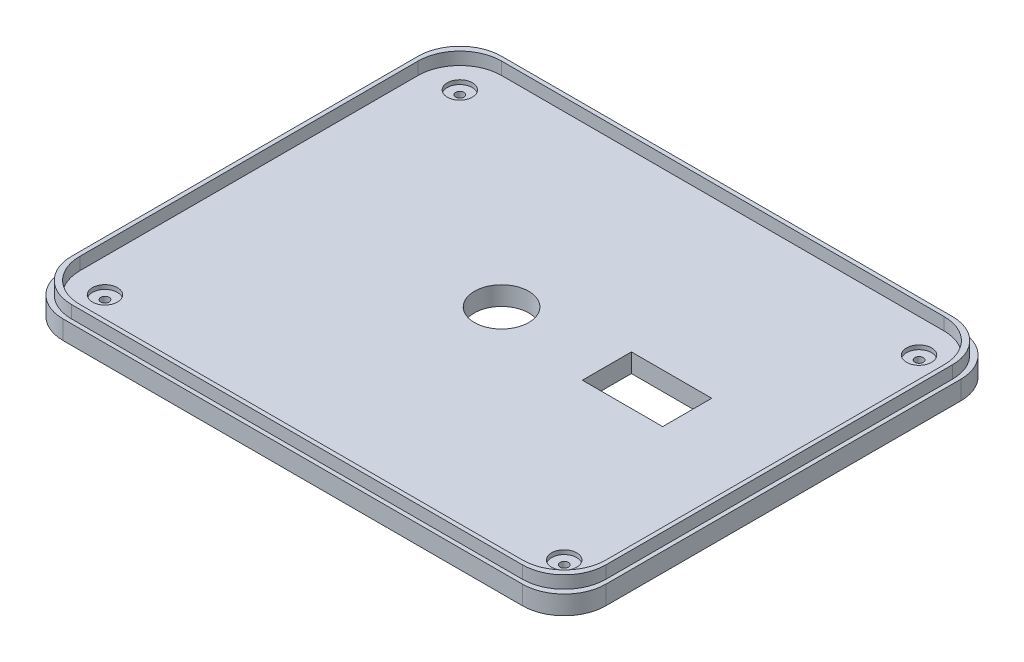
from build123d import *

# Parameters (mm, degrees)
SKETCH_1_R          = 6.5
EXTRUDE_1_DEPTH     = 4.5
EXTRUDE_2_DEPTH     = 3
SKETCH_3_R          = 1
CUT_EXTRUDE_1_DEPTH = 10
SKETCH_4_R          = 3
CUT_EXTRUDE_2_DEPTH = 1
SKETCH_5_R          = 3
CUT_EXTRUDE_3_DEPTH = 1.5
SKETCH_6_W          = 19.238645782
SKETCH_6_H          = 11.749776954
CUT_EXTRUDE_6_DEPTH = 10


with BuildPart() as part:
    # 草图1 → 凸台-拉伸1 (new body)
    with BuildSketch(Plane(origin=(0, 0, 0), x_dir=(1, 0, 0), z_dir=(0, 1, 0))):
        with BuildLine():
            Line((-50.483870968, 65.483870968), (59.516129032, 65.483870968))
            ThreePointArc((59.516129032, 65.483870968), (66.587196844, 62.55493878), (69.516129032, 55.483870968))
            Line((69.516129032, 55.483870968), (69.516129032, -29.516129032))
            ThreePointArc((69.516129032, -29.516129032), (66.587196844, -36.587196844), (59.516129032, -39.516129032))
            Line((59.516129032, -39.516129032), (-50.483870968, -39.516129032))
            ThreePointArc((-50.483870968, -39.516129032), (-57.55493878, -36.587196844), (-60.483870968, -29.516129032))
            Line((-60.483870968, -29.516129032), (-60.483870968, 55.483870968))
            ThreePointArc((-60.483870968, 55.483870968), (-57.55493878, 62.55493878), (-50.483870968, 65.483870968))
        make_face()
        with Locations((-0.483870968, 15.483870968)):
            Circle(SKETCH_1_R, mode=Mode.SUBTRACT)
    extrude(amount=EXTRUDE_1_DEPTH)

    # 草图2 → 凸台-拉伸2 (add)
    with BuildSketch(Plane(origin=(0, 4.5, 0), x_dir=(1, 0, 0), z_dir=(0, 1, 0))):
        with BuildLine():
            Line((-49.483870968, 64.483870968), (58.516129032, 64.483870968))
            ThreePointArc((58.516129032, 64.483870968), (65.587196844, 61.55493878), (68.516129032, 54.483870968))
            Line((68.516129032, 54.483870968), (68.516129032, -28.516129032))
            ThreePointArc((68.516129032, -28.516129032), (65.587196844, -35.587196844), (58.516129032, -38.516129032))
            Line((58.516129032, -38.516129032), (-49.483870968, -38.516129032))
            ThreePointArc((-49.483870968, -38.516129032), (-56.55493878, -35.587196844), (-59.483870968, -28.516129032))
            Line((-59.483870968, -28.516129032), (-59.483870968, 54.483870968))
            ThreePointArc((-59.483870968, 54.483870968), (-56.55493878, 61.55493878), (-49.483870968, 64.483870968))
        make_face()
        with BuildLine():
            Line((-48.483870968, 63.483870968), (57.516129032, 63.483870968))
            ThreePointArc((57.516129032, 63.483870968), (64.587196844, 60.55493878), (67.516129032, 53.483870968))
            Line((67.516129032, 53.483870968), (67.516129032, -27.516129032))
            ThreePointArc((67.516129032, -27.516129032), (64.587196844, -34.587196844), (57.516129032, -37.516129032))
            Line((57.516129032, -37.516129032), (-48.483870968, -37.516129032))
            ThreePointArc((-48.483870968, -37.516129032), (-55.55493878, -34.587196844), (-58.483870968, -27.516129032))
            Line((-58.483870968, -27.516129032), (-58.483870968, 53.483870968))
            ThreePointArc((-58.483870968, 53.483870968), (-55.55493878, 60.55493878), (-48.483870968, 63.483870968))
        make_face(mode=Mode.SUBTRACT)
    extrude(amount=EXTRUDE_2_DEPTH)

    # 草图3 → 切除-拉伸1 (cut)
    with BuildSketch(Plane(origin=(0, 4.5, 0), x_dir=(1, 0, 0), z_dir=(0, 1, 0))):
        with Locations((-50.483870968, 55.483870968)):
            Circle(SKETCH_3_R)
        with Locations((-50.483870968, -29.516129032)):
            Circle(SKETCH_3_R)
        with Locations((59.516129032, -29.516129032)):
            Circle(SKETCH_3_R)
        with Locations((59.516129032, 55.483870968)):
            Circle(SKETCH_3_R)
    extrude(amount=-CUT_EXTRUDE_1_DEPTH, mode=Mode.SUBTRACT)

    # 草图4 → 切除-拉伸2 (cut)
    with BuildSketch(Plane(origin=(0, 4.5, 0), x_dir=(1, 0, 0), z_dir=(0, 1, 0))):
        with Locations((-50.483870968, 55.483870968)):
            Circle(SKETCH_4_R)
        with Locations((59.516129032, 55.483870968)):
            Circle(SKETCH_4_R)
        with Locations((59.516129032, -29.516129032)):
            Circle(SKETCH_4_R)
        with Locations((-50.483870968, -29.516129032)):
            Circle(SKETCH_4_R)
    extrude(amount=-CUT_EXTRUDE_2_DEPTH, mode=Mode.SUBTRACT)

    # 草图5 → 切除-拉伸3 (cut)
    with BuildSketch(Plane.XZ):
        with Locations((-50.483870968, 29.516129032)):
            Circle(SKETCH_5_R)
        with Locations((59.516129032, 29.516129032)):
            Circle(SKETCH_5_R)
        with Locations((59.516129032, -55.483870968)):
            Circle(SKETCH_5_R)
        with Locations((-50.483870968, -55.483870968)):
            Circle(SKETCH_5_R)
    extrude(amount=-CUT_EXTRUDE_3_DEPTH, mode=Mode.SUBTRACT)

    # 草图6 → 切除-拉伸6 (cut)
    with BuildSketch(Plane(origin=(0, 4.5, 0), x_dir=(1, 0, 0), z_dir=(0, 1, 0))):
        with Locations((34.019689846, 15.824476385)):
            Rectangle(SKETCH_6_W, SKETCH_6_H)
    extrude(amount=-CUT_EXTRUDE_6_DEPTH, mode=Mode.SUBTRACT)


solid = part.part
